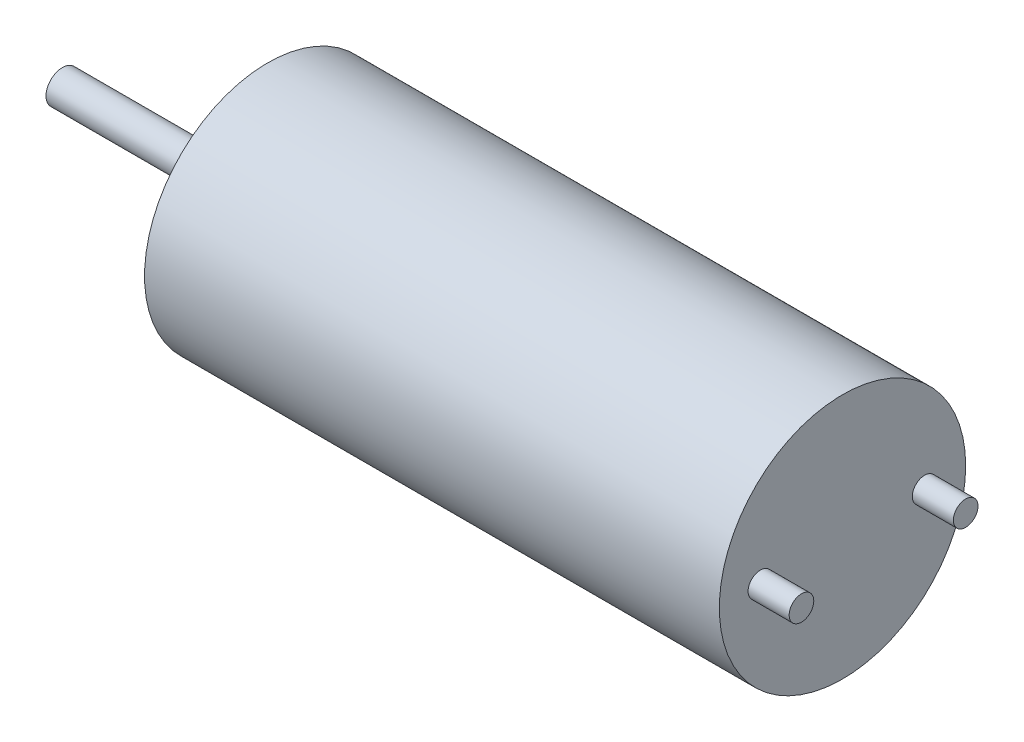
from build123d import *

# Parameters (mm, degrees)
SKETCH1_R           = 3
BOSS_EXTRUDE1_DEPTH = 14
SKETCH2_R           = 1.2
BOSS_EXTRUDE2_DEPTH = 0.8
SKETCH3_R           = 0.4
BOSS_EXTRUDE3_DEPTH = 4.2
SKETCH4_R           = 0.3
BOSS_EXTRUDE4_DEPTH = 1


with BuildPart() as part:
    # Sketch1 → Boss-Extrude1 (new body)
    with BuildSketch(Plane(origin=(0, 0, 0), x_dir=(0, 0, -1), z_dir=(1, 0, 0))):
        Circle(SKETCH1_R)
    extrude(amount=BOSS_EXTRUDE1_DEPTH)

    # Sketch2 → Boss-Extrude2 (add)
    with BuildSketch(Plane.ZY):
        Circle(SKETCH2_R)
    extrude(amount=BOSS_EXTRUDE2_DEPTH)

    # Sketch3 → Boss-Extrude3 (add)
    with BuildSketch(Plane.ZY.offset(0.8)):
        Circle(SKETCH3_R)
    extrude(amount=BOSS_EXTRUDE3_DEPTH)

    # Sketch4 → Boss-Extrude4 (add)
    with BuildSketch(Plane(origin=(14, 0, 0), x_dir=(0, 0, -1), z_dir=(1, 0, 0))):
        with Locations((-2, 0)):
            Circle(SKETCH4_R)
        with Locations((2, 0)):
            Circle(SKETCH4_R)
    extrude(amount=BOSS_EXTRUDE4_DEPTH)


solid = part.part
